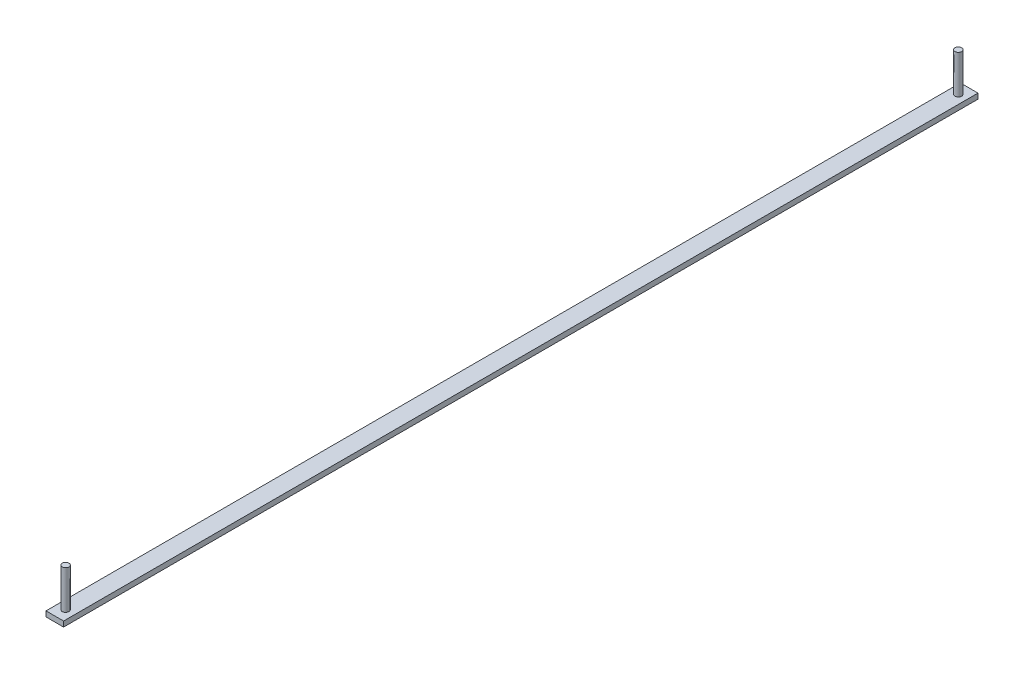
from build123d import *

# Parameters (mm, degrees)
SKETCH1_W           = 25.4
SKETCH1_H           = 1320.8
BOSS_EXTRUDE1_DEPTH = 7.62
SKETCH2_R           = 4.826
BOSS_EXTRUDE2_DEPTH = 55.88


with BuildPart() as part:
    # Sketch1 → Boss-Extrude1 (new body)
    with BuildSketch(Plane(origin=(0, 0, 0), x_dir=(1, 0, 0), z_dir=(0, 1, 0))):
        with Locations((12.7, 660.4)):
            Rectangle(SKETCH1_W, SKETCH1_H)
    extrude(amount=BOSS_EXTRUDE1_DEPTH)

    # Sketch2 → Boss-Extrude2 (add)
    with BuildSketch(Plane(origin=(0, 7.62, 0), x_dir=(1, 0, 0), z_dir=(0, 1, 0))):
        with Locations((12.7, 15.621)):
            Circle(SKETCH2_R)
        with Locations((12.7, 1305.052)):
            Circle(SKETCH2_R)
    extrude(amount=BOSS_EXTRUDE2_DEPTH)


solid = part.part
